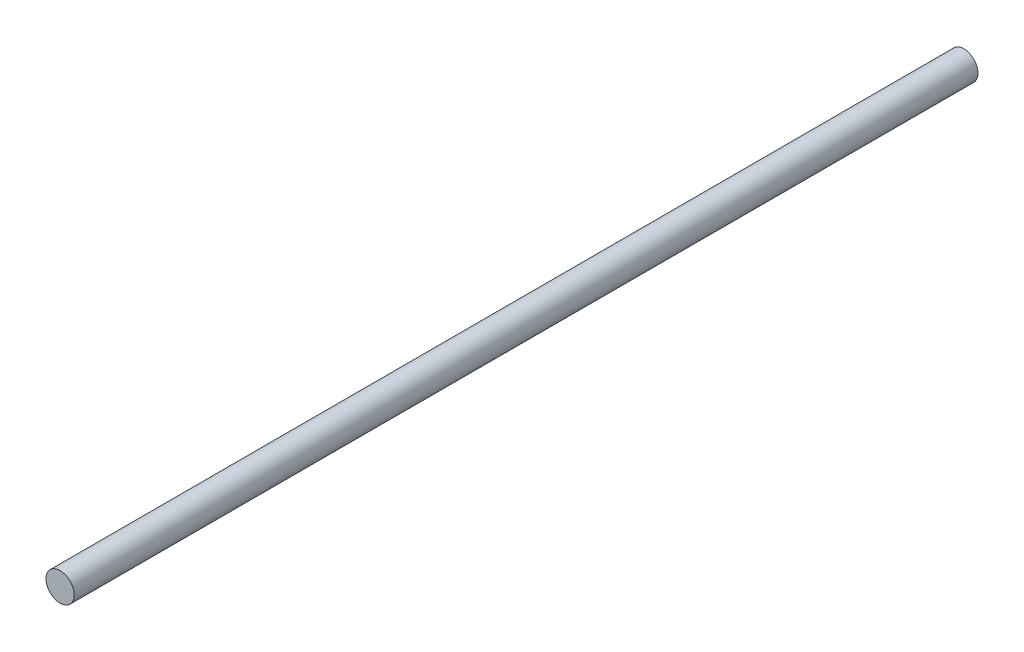
from build123d import *

# Parameters (mm, degrees)
SKETCH1_R           = 3.175
BOSS_EXTRUDE1_DEPTH = 203.2


with BuildPart() as part:
    # Sketch1 → Boss-Extrude1 (new body)
    with BuildSketch(Plane.XY):
        Circle(SKETCH1_R)
    extrude(amount=BOSS_EXTRUDE1_DEPTH)


solid = part.part
